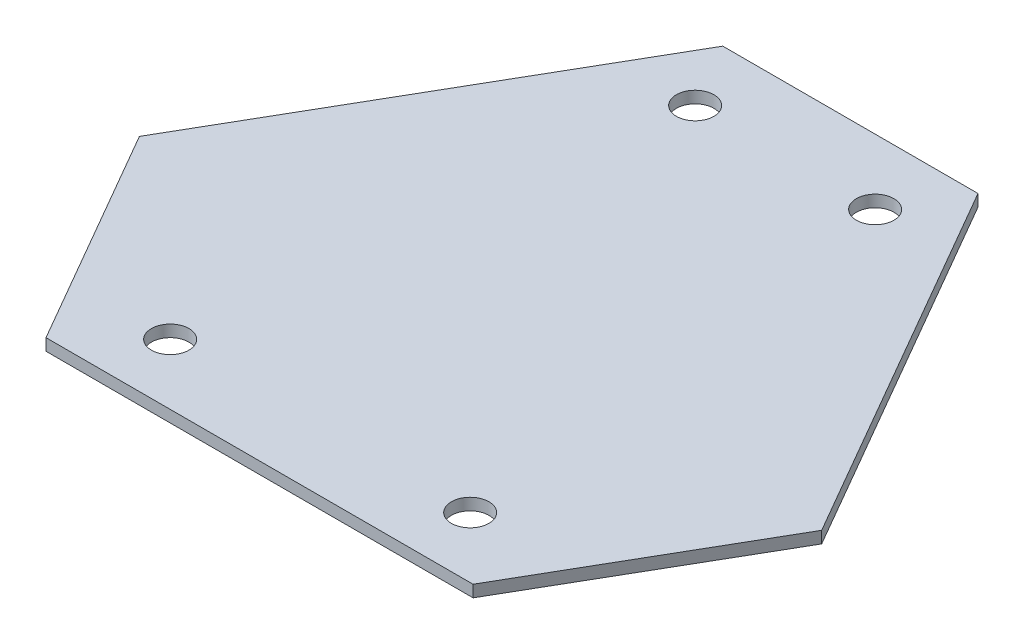
from build123d import *

# Parameters (mm, degrees)
SKETCH1_R           = 1.27
BOSS_EXTRUDE1_DEPTH = 0.8


with BuildPart() as part:
    # Sketch1 → Boss-Extrude1 (new body)
    with BuildSketch(Plane(origin=(0, 0, 0), x_dir=(1, 0, 0), z_dir=(0, 1, 0))):
        Polygon((-23.106984432, -3.360728953), (-8.643015568, 21.6916), (8.643015568, 21.6916), (23.106984432, -3.360728953), (14.463968865, -18.330871047), (-14.463968865, -18.330871047), align=None)
        with Locations((-6.096, 17.272)):
            Circle(SKETCH1_R, mode=Mode.SUBTRACT)
        with Locations((-10.16, -14.224)):
            Circle(SKETCH1_R, mode=Mode.SUBTRACT)
        with Locations((10.16, -14.224)):
            Circle(SKETCH1_R, mode=Mode.SUBTRACT)
        with Locations((6.096, 17.272)):
            Circle(SKETCH1_R, mode=Mode.SUBTRACT)
    extrude(amount=BOSS_EXTRUDE1_DEPTH)


solid = part.part
